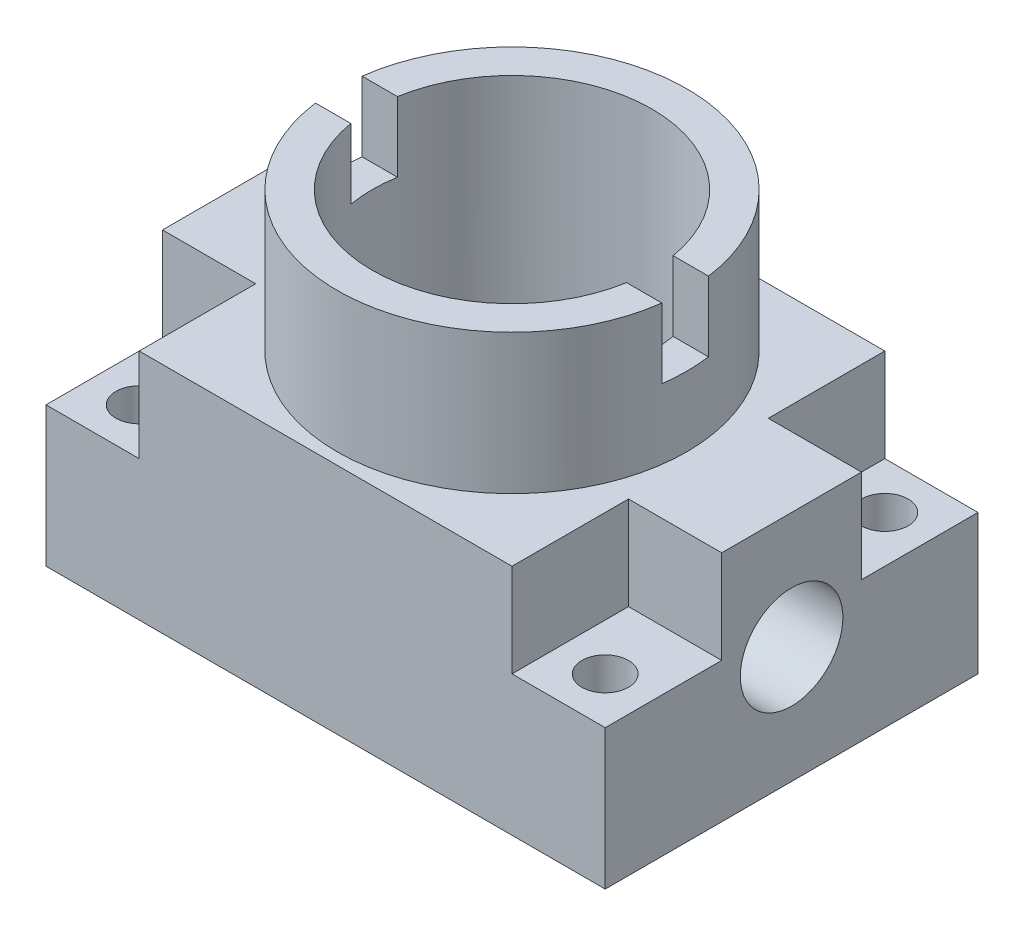
from build123d import *

# Parameters (mm, degrees)
SKETCH_1_W          = 120
SKETCH_1_H          = 80
EXTRUDE_1_DEPTH     = 50
SKETCH_2_W          = 20
SKETCH_2_H          = 25
CUT_EXTRUDE_1_DEPTH = 20
SKETCH_3_R          = 5
CUT_EXTRUDE_2_DEPTH = 30
SKETCH_5_R          = 11
CUT_EXTRUDE_4_DEPTH = 120
SKETCH_6_R          = 37.5
EXTRUDE_2_DEPTH     = 30
SKETCH_7_R          = 30
CUT_EXTRUDE_5_DEPTH = 81
CUT_EXTRUDE_6_DEPTH = 15


with BuildPart() as part:
    # Эскиз1 → Бобышка-Вытянуть1 (new body)
    with BuildSketch(Plane(origin=(0, 0, 0), x_dir=(1, 0, 0), z_dir=(0, 1, 0))):
        Rectangle(SKETCH_1_W, SKETCH_1_H)
    extrude(amount=EXTRUDE_1_DEPTH)

    # Эскиз2 → Вырез-Вытянуть1 (cut)
    with BuildSketch(Plane(origin=(0, 50, 0), x_dir=(1, 0, 0), z_dir=(0, 1, 0))):
        with Locations((-50, 27.5)):
            Rectangle(SKETCH_2_W, SKETCH_2_H)
        with Locations((-50, -27.5)):
            Rectangle(SKETCH_2_W, SKETCH_2_H)
        with Locations((50, -27.5)):
            Rectangle(SKETCH_2_W, SKETCH_2_H)
        with Locations((50, 27.5)):
            Rectangle(SKETCH_2_W, SKETCH_2_H)
    extrude(amount=-CUT_EXTRUDE_1_DEPTH, mode=Mode.SUBTRACT)

    # Эскиз3 → Вырез-Вытянуть2 (cut)
    with BuildSketch(Plane(origin=(0, 30, 0), x_dir=(1, 0, 0), z_dir=(0, 1, 0))):
        with Locations((-50, -30)):
            Circle(SKETCH_3_R)
        with Locations((-50, 30)):
            Circle(SKETCH_3_R)
        with Locations((50, 30)):
            Circle(SKETCH_3_R)
        with Locations((50, -30)):
            Circle(SKETCH_3_R)
    extrude(amount=-CUT_EXTRUDE_2_DEPTH, mode=Mode.SUBTRACT)

    # Эскиз5 → Вырез-Вытянуть4 (cut)
    with BuildSketch(Plane.ZY.offset(60)):
        with Locations((0, 25)):
            Circle(SKETCH_5_R)
    extrude(amount=-CUT_EXTRUDE_4_DEPTH, mode=Mode.SUBTRACT)

    # Эскиз6 → Бобышка-Вытянуть2 (add)
    with BuildSketch(Plane(origin=(0, 50, 0), x_dir=(1, 0, 0), z_dir=(0, 1, 0))):
        Circle(SKETCH_6_R)
    extrude(amount=EXTRUDE_2_DEPTH)

    # Эскиз7 → Вырез-Вытянуть5 (cut, through all)
    with BuildSketch(Plane(origin=(0, 80, 0), x_dir=(1, 0, 0), z_dir=(0, 1, 0))):
        Circle(SKETCH_7_R)
    extrude(amount=-CUT_EXTRUDE_5_DEPTH, mode=Mode.SUBTRACT)

    # Эскиз8 → Вырез-Вытянуть6 (cut)
    with BuildSketch(Plane(origin=(0, 80, 0), x_dir=(1, 0, 0), z_dir=(0, 1, 0))):
        with BuildLine():
            Line((-29.580398915, -5), (-37.165171868, -5))
            ThreePointArc((-37.165171868, -5), (-37.5, 0), (-37.165171868, 5))
            Line((-37.165171868, 5), (-29.580398915, 5))
            ThreePointArc((-29.580398915, 5), (-30, 0), (-29.580398915, -5))
        make_face()
        with BuildLine():
            Line((37.165171868, 5), (29.580398915, 5))
            ThreePointArc((29.580398915, 5), (30, 0), (29.580398915, -5))
            Line((29.580398915, -5), (37.165171868, -5))
            ThreePointArc((37.165171868, -5), (37.5, 0), (37.165171868, 5))
        make_face()
    extrude(amount=-CUT_EXTRUDE_6_DEPTH, mode=Mode.SUBTRACT)


solid = part.part
